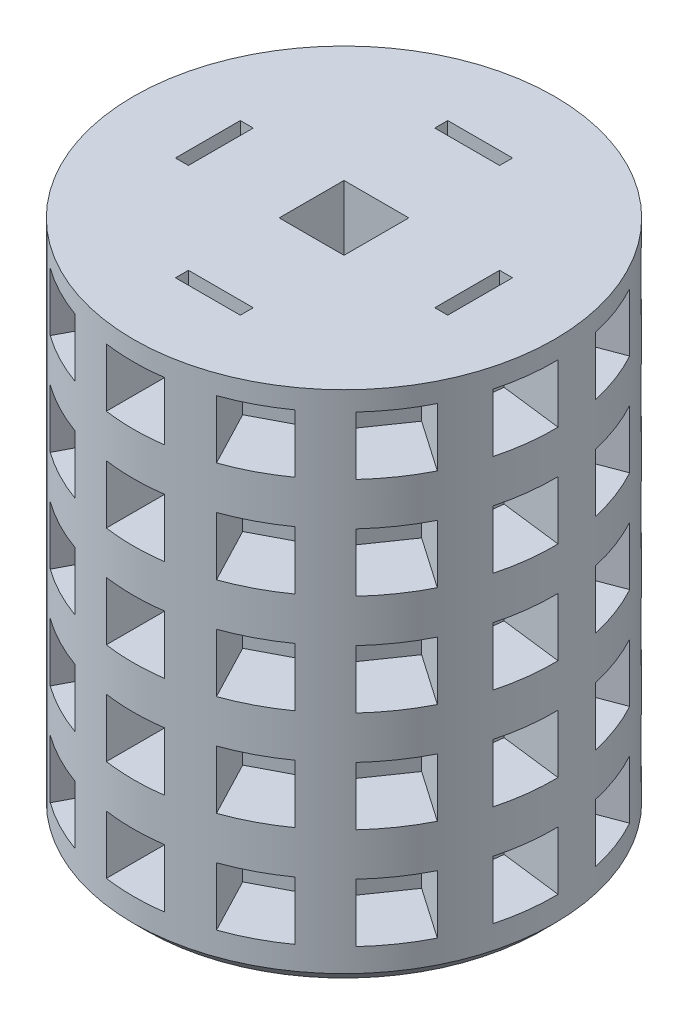
from build123d import *

# Parameters (mm, degrees)
SKETCH1_R                  = 41.2369
BOSS_EXTRUDE1_DEPTH        = 203.2
CUT_EXTRUDE1_DEPTH         = 204.2
CHAMFER1_SIZE              = 2.54
CHAMFER2_SIZE              = 2.54
CUT_EXTRUDE3_DEPTH         = 12.7
LPATTERN1_COUNT            = 10
LPATTERN1_PITCH            = 19.812
CIRPATTERN1_COUNT          = 13
CIRPATTERN1_ANGLE          = 332.4
CIRPATTERN1_COPY_1_DEPTH   = 12.7
CIRPATTERN1_COPY_2_DEPTH   = 12.7
CIRPATTERN1_COPY_3_DEPTH   = 12.7
CIRPATTERN1_COPY_4_DEPTH   = 12.7
CIRPATTERN1_COPY_5_DEPTH   = 12.7
CIRPATTERN1_COPY_6_DEPTH   = 12.7
CIRPATTERN1_COPY_7_DEPTH   = 12.7
CIRPATTERN1_COPY_8_DEPTH   = 12.7
CIRPATTERN1_COPY_9_DEPTH   = 12.7
CIRPATTERN1_COPY_10_DEPTH  = 12.7
CIRPATTERN1_COPY_11_DEPTH  = 12.7
CIRPATTERN1_COPY_12_DEPTH  = 12.7
CIRPATTERN1_COPY_13_DEPTH  = 12.7
CIRPATTERN1_COPY_14_DEPTH  = 12.7
CIRPATTERN1_COPY_15_DEPTH  = 12.7
CIRPATTERN1_COPY_16_DEPTH  = 12.7
CIRPATTERN1_COPY_17_DEPTH  = 12.7
CIRPATTERN1_COPY_18_DEPTH  = 12.7
CIRPATTERN1_COPY_19_DEPTH  = 12.7
CIRPATTERN1_COPY_20_DEPTH  = 12.7
CIRPATTERN1_COPY_21_DEPTH  = 12.7
CIRPATTERN1_COPY_22_DEPTH  = 12.7
CIRPATTERN1_COPY_23_DEPTH  = 12.7
CIRPATTERN1_COPY_24_DEPTH  = 12.7
CIRPATTERN1_COPY_25_DEPTH  = 12.7
CIRPATTERN1_COPY_26_DEPTH  = 12.7
CIRPATTERN1_COPY_27_DEPTH  = 12.7
CIRPATTERN1_COPY_28_DEPTH  = 12.7
CIRPATTERN1_COPY_29_DEPTH  = 12.7
CIRPATTERN1_COPY_30_DEPTH  = 12.7
CIRPATTERN1_COPY_31_DEPTH  = 12.7
CIRPATTERN1_COPY_32_DEPTH  = 12.7
CIRPATTERN1_COPY_33_DEPTH  = 12.7
CIRPATTERN1_COPY_34_DEPTH  = 12.7
CIRPATTERN1_COPY_35_DEPTH  = 12.7
CIRPATTERN1_COPY_36_DEPTH  = 12.7
CIRPATTERN1_COPY_37_DEPTH  = 12.7
CIRPATTERN1_COPY_38_DEPTH  = 12.7
CIRPATTERN1_COPY_39_DEPTH  = 12.7
CIRPATTERN1_COPY_40_DEPTH  = 12.7
CIRPATTERN1_COPY_41_DEPTH  = 12.7
CIRPATTERN1_COPY_42_DEPTH  = 12.7
CIRPATTERN1_COPY_43_DEPTH  = 12.7
CIRPATTERN1_COPY_44_DEPTH  = 12.7
CIRPATTERN1_COPY_45_DEPTH  = 12.7
CIRPATTERN1_COPY_46_DEPTH  = 12.7
CIRPATTERN1_COPY_47_DEPTH  = 12.7
CIRPATTERN1_COPY_48_DEPTH  = 12.7
CIRPATTERN1_COPY_49_DEPTH  = 12.7
CIRPATTERN1_COPY_50_DEPTH  = 12.7
CIRPATTERN1_COPY_51_DEPTH  = 12.7
CIRPATTERN1_COPY_52_DEPTH  = 12.7
CIRPATTERN1_COPY_53_DEPTH  = 12.7
CIRPATTERN1_COPY_54_DEPTH  = 12.7
CIRPATTERN1_COPY_55_DEPTH  = 12.7
CIRPATTERN1_COPY_56_DEPTH  = 12.7
CIRPATTERN1_COPY_57_DEPTH  = 12.7
CIRPATTERN1_COPY_58_DEPTH  = 12.7
CIRPATTERN1_COPY_59_DEPTH  = 12.7
CIRPATTERN1_COPY_60_DEPTH  = 12.7
CIRPATTERN1_COPY_61_DEPTH  = 12.7
CIRPATTERN1_COPY_62_DEPTH  = 12.7
CIRPATTERN1_COPY_63_DEPTH  = 12.7
CIRPATTERN1_COPY_64_DEPTH  = 12.7
CIRPATTERN1_COPY_65_DEPTH  = 12.7
CIRPATTERN1_COPY_66_DEPTH  = 12.7
CIRPATTERN1_COPY_67_DEPTH  = 12.7
CIRPATTERN1_COPY_68_DEPTH  = 12.7
CIRPATTERN1_COPY_69_DEPTH  = 12.7
CIRPATTERN1_COPY_70_DEPTH  = 12.7
CIRPATTERN1_COPY_71_DEPTH  = 12.7
CIRPATTERN1_COPY_72_DEPTH  = 12.7
CIRPATTERN1_COPY_73_DEPTH  = 12.7
CIRPATTERN1_COPY_74_DEPTH  = 12.7
CIRPATTERN1_COPY_75_DEPTH  = 12.7
CIRPATTERN1_COPY_76_DEPTH  = 12.7
CIRPATTERN1_COPY_77_DEPTH  = 12.7
CIRPATTERN1_COPY_78_DEPTH  = 12.7
CIRPATTERN1_COPY_79_DEPTH  = 12.7
CIRPATTERN1_COPY_80_DEPTH  = 12.7
CIRPATTERN1_COPY_81_DEPTH  = 12.7
CIRPATTERN1_COPY_82_DEPTH  = 12.7
CIRPATTERN1_COPY_83_DEPTH  = 12.7
CIRPATTERN1_COPY_84_DEPTH  = 12.7
CIRPATTERN1_COPY_85_DEPTH  = 12.7
CIRPATTERN1_COPY_86_DEPTH  = 12.7
CIRPATTERN1_COPY_87_DEPTH  = 12.7
CIRPATTERN1_COPY_88_DEPTH  = 12.7
CIRPATTERN1_COPY_89_DEPTH  = 12.7
CIRPATTERN1_COPY_90_DEPTH  = 12.7
CIRPATTERN1_COPY_91_DEPTH  = 12.7
CIRPATTERN1_COPY_92_DEPTH  = 12.7
CIRPATTERN1_COPY_93_DEPTH  = 12.7
CIRPATTERN1_COPY_94_DEPTH  = 12.7
CIRPATTERN1_COPY_95_DEPTH  = 12.7
CIRPATTERN1_COPY_96_DEPTH  = 12.7
CIRPATTERN1_COPY_97_DEPTH  = 12.7
CIRPATTERN1_COPY_98_DEPTH  = 12.7
CIRPATTERN1_COPY_99_DEPTH  = 12.7
CIRPATTERN1_COPY_100_DEPTH = 12.7
CIRPATTERN1_COPY_101_DEPTH = 12.7
CIRPATTERN1_COPY_102_DEPTH = 12.7
CIRPATTERN1_COPY_103_DEPTH = 12.7
CIRPATTERN1_COPY_104_DEPTH = 12.7
CIRPATTERN1_COPY_105_DEPTH = 12.7
CIRPATTERN1_COPY_106_DEPTH = 12.7
CIRPATTERN1_COPY_107_DEPTH = 12.7
CIRPATTERN1_COPY_108_DEPTH = 12.7
SKETCH7_R                  = 41.2369
CUT_EXTRUDE4_DEPTH         = 101.6
SKETCH9_R                  = 20.32
SKETCH9_W                  = 12.7
SKETCH9_H                  = 12.7
BOSS_EXTRUDE4_DEPTH        = 9.906
SKETCH8_W                  = 12.7
SKETCH8_H                  = 2.54
SKETCH8_W_2                = 2.54
SKETCH8_H_2                = 12.7
CUT_EXTRUDE6_DEPTH         = 12.7


with BuildPart() as part:
    # Sketch1 → Boss-Extrude1 (new body)
    with BuildSketch(Plane(origin=(0, 0, 0), x_dir=(1, 0, 0), z_dir=(0, 1, 0))):
        Circle(SKETCH1_R)
    extrude(amount=BOSS_EXTRUDE1_DEPTH)

    # Sketch2 → Cut-Extrude1 (cut, through all)
    with BuildSketch(Plane(origin=(0, 0, 0), x_dir=(-1, 0, 0), z_dir=(0, -1, 0))):
        Polygon((0, -6.35), (6.35, -6.35), (6.35, 6.35), (0, 6.35), (-6.35, 6.35), (-6.35, -6.35), align=None)
    extrude(amount=-CUT_EXTRUDE1_DEPTH, mode=Mode.SUBTRACT)

    # Chamfer1
    chamfer1_edges = [part.edges().sort_by_distance(p)[0] for p in [
        (-41.2369, 203.2, 0),
    ]]
    chamfer(chamfer1_edges, length=CHAMFER1_SIZE)

    # Chamfer2
    chamfer2_edges = [part.edges().sort_by_distance(p)[0] for p in [
        (-41.2369, 0, 0),
    ]]
    chamfer(chamfer2_edges, length=CHAMFER2_SIZE)

    # Sketch6 → Cut-Extrude3 (cut)
    with BuildSketch(Plane.XY.offset(41.402)):
        Polygon((0, 196.85), (5.715, 196.85), (5.715, 191.135), (5.715, 185.42), (-5.715, 185.42), (-5.715, 191.135), (-5.715, 196.85), align=None)
    cut_extrude3 = extrude(amount=-CUT_EXTRUDE3_DEPTH, mode=Mode.SUBTRACT)

    # LPattern1: Cut-Extrude3 ×10
    with Locations(*[(0, -i * LPATTERN1_PITCH, 0) for i in range(1, LPATTERN1_COUNT)]):
        add(cut_extrude3, mode=Mode.SUBTRACT)

    # CirPattern1: Cut-Extrude3 ×13 about axis
    cirpattern1_axis = Axis((0, 0, 0), (0, -1, 0))
    for i in range(1, CIRPATTERN1_COUNT):
        add(cut_extrude3.rotate(cirpattern1_axis, i * CIRPATTERN1_ANGLE / (CIRPATTERN1_COUNT - 1)), mode=Mode.SUBTRACT)

    # CirPattern1 copy 1 sketch → CirPattern1 copy 1 (cut)
    with BuildSketch(Plane(origin=(-19.245390377, -19.812, 36.657066893), x_dir=(0.885393626, 0, 0.464842046), z_dir=(-0.464842046, 0, 0.885393626))):
        Polygon((0, 196.85), (5.715, 196.85), (5.715, 191.135), (5.715, 185.42), (-5.715, 185.42), (-5.715, 191.135), (-5.715, 196.85), align=None)
    extrude(amount=-CIRPATTERN1_COPY_1_DEPTH, mode=Mode.SUBTRACT)

    # CirPattern1 copy 2 sketch → CirPattern1 copy 2 (cut)
    with BuildSketch(Plane(origin=(-34.07949193, -19.812, 23.509866733), x_dir=(0.567843745, 0, 0.823136369), z_dir=(-0.823136369, 0, 0.567843745))):
        Polygon((0, 196.85), (5.715, 196.85), (5.715, 191.135), (5.715, 185.42), (-5.715, 185.42), (-5.715, 191.135), (-5.715, 196.85), align=None)
    extrude(amount=-CIRPATTERN1_COPY_2_DEPTH, mode=Mode.SUBTRACT)

    # CirPattern1 copy 3 sketch → CirPattern1 copy 3 (cut)
    with BuildSketch(Plane(origin=(-41.102139471, -19.812, 4.973905401), x_dir=(0.120136839, 0, 0.992757342), z_dir=(-0.992757342, 0, 0.120136839))):
        Polygon((0, 196.85), (5.715, 196.85), (5.715, 191.135), (5.715, 185.42), (-5.715, 185.42), (-5.715, 191.135), (-5.715, 196.85), align=None)
    extrude(amount=-CIRPATTERN1_COPY_3_DEPTH, mode=Mode.SUBTRACT)

    # CirPattern1 copy 4 sketch → CirPattern1 copy 4 (cut)
    with BuildSketch(Plane(origin=(-38.703652654, -19.812, -14.702138458), x_dir=(-0.355106962, 0, 0.934825676), z_dir=(-0.934825676, 0, -0.355106962))):
        Polygon((0, 196.85), (5.715, 196.85), (5.715, 191.135), (5.715, 185.42), (-5.715, 185.42), (-5.715, 191.135), (-5.715, 196.85), align=None)
    extrude(amount=-CIRPATTERN1_COPY_4_DEPTH, mode=Mode.SUBTRACT)

    # CirPattern1 copy 5 sketch → CirPattern1 copy 5 (cut)
    with BuildSketch(Plane(origin=(-27.433795236, -19.812, -31.008264752), x_dir=(-0.748955721, 0, 0.662620048), z_dir=(-0.662620048, 0, -0.748955721))):
        Polygon((0, 196.85), (5.715, 196.85), (5.715, 191.135), (5.715, 185.42), (-5.715, 185.42), (-5.715, 191.135), (-5.715, 196.85), align=None)
    extrude(amount=-CIRPATTERN1_COPY_5_DEPTH, mode=Mode.SUBTRACT)

    # CirPattern1 copy 6 sketch → CirPattern1 copy 6 (cut)
    with BuildSketch(Plane(origin=(-9.875762211, -19.812, -40.206901457), x_dir=(-0.97113428, 0, 0.238533458), z_dir=(-0.238533458, 0, -0.97113428))):
        Polygon((0, 196.85), (5.715, 196.85), (5.715, 191.135), (5.715, 185.42), (-5.715, 185.42), (-5.715, 191.135), (-5.715, 196.85), align=None)
    extrude(amount=-CIRPATTERN1_COPY_6_DEPTH, mode=Mode.SUBTRACT)

    # CirPattern1 copy 7 sketch → CirPattern1 copy 7 (cut)
    with BuildSketch(Plane(origin=(9.945921415, -19.812, -40.18960377), x_dir=(-0.970716482, 0, -0.240228042), z_dir=(0.240228042, 0, -0.970716482))):
        Polygon((0, 196.85), (5.715, 196.85), (5.715, 191.135), (5.715, 185.42), (-5.715, 185.42), (-5.715, 191.135), (-5.715, 196.85), align=None)
    extrude(amount=-CIRPATTERN1_COPY_7_DEPTH, mode=Mode.SUBTRACT)

    # CirPattern1 copy 8 sketch → CirPattern1 copy 8 (cut)
    with BuildSketch(Plane(origin=(27.487873056, -19.812, -30.960336543), x_dir=(-0.74779809, 0, -0.663926213), z_dir=(0.663926213, 0, -0.74779809))):
        Polygon((0, 196.85), (5.715, 196.85), (5.715, 191.135), (5.715, 185.42), (-5.715, 185.42), (-5.715, 191.135), (-5.715, 196.85), align=None)
    extrude(amount=-CIRPATTERN1_COPY_8_DEPTH, mode=Mode.SUBTRACT)

    # CirPattern1 copy 9 sketch → CirPattern1 copy 9 (cut)
    with BuildSketch(Plane(origin=(38.729253764, -19.812, -14.634565482), x_dir=(-0.353474844, 0, -0.935444031), z_dir=(0.935444031, 0, -0.353474844))):
        Polygon((0, 196.85), (5.715, 196.85), (5.715, 191.135), (5.715, 185.42), (-5.715, 185.42), (-5.715, 191.135), (-5.715, 196.85), align=None)
    extrude(amount=-CIRPATTERN1_COPY_9_DEPTH, mode=Mode.SUBTRACT)

    # CirPattern1 copy 10 sketch → CirPattern1 copy 10 (cut)
    with BuildSketch(Plane(origin=(41.09339577, -19.812, 5.045634556), x_dir=(0.121869343, 0, -0.992546152), z_dir=(0.992546152, 0, 0.121869343))):
        Polygon((0, 196.85), (5.715, 196.85), (5.715, 191.135), (5.715, 185.42), (-5.715, 185.42), (-5.715, 191.135), (-5.715, 196.85), align=None)
    extrude(amount=-CIRPATTERN1_COPY_10_DEPTH, mode=Mode.SUBTRACT)

    # CirPattern1 copy 11 sketch → CirPattern1 copy 11 (cut)
    with BuildSketch(Plane(origin=(34.038407587, -19.812, 23.569310829), x_dir=(0.569279523, 0, -0.822144041), z_dir=(0.822144041, 0, 0.569279523))):
        Polygon((0, 196.85), (5.715, 196.85), (5.715, 191.135), (5.715, 185.42), (-5.715, 185.42), (-5.715, 191.135), (-5.715, 196.85), align=None)
    extrude(amount=-CIRPATTERN1_COPY_11_DEPTH, mode=Mode.SUBTRACT)

    # CirPattern1 copy 12 sketch → CirPattern1 copy 12 (cut)
    with BuildSketch(Plane(origin=(19.181382446, -19.812, 36.690600587), x_dir=(0.886203579, 0, -0.463296035), z_dir=(0.463296035, 0, 0.886203579))):
        Polygon((0, 196.85), (5.715, 196.85), (5.715, 191.135), (5.715, 185.42), (-5.715, 185.42), (-5.715, 191.135), (-5.715, 196.85), align=None)
    extrude(amount=-CIRPATTERN1_COPY_12_DEPTH, mode=Mode.SUBTRACT)

    # CirPattern1 copy 13 sketch → CirPattern1 copy 13 (cut)
    with BuildSketch(Plane(origin=(-19.245390377, -39.624, 36.657066893), x_dir=(0.885393626, 0, 0.464842046), z_dir=(-0.464842046, 0, 0.885393626))):
        Polygon((0, 196.85), (5.715, 196.85), (5.715, 191.135), (5.715, 185.42), (-5.715, 185.42), (-5.715, 191.135), (-5.715, 196.85), align=None)
    extrude(amount=-CIRPATTERN1_COPY_13_DEPTH, mode=Mode.SUBTRACT)

    # CirPattern1 copy 14 sketch → CirPattern1 copy 14 (cut)
    with BuildSketch(Plane(origin=(-34.07949193, -39.624, 23.509866733), x_dir=(0.567843745, 0, 0.823136369), z_dir=(-0.823136369, 0, 0.567843745))):
        Polygon((0, 196.85), (5.715, 196.85), (5.715, 191.135), (5.715, 185.42), (-5.715, 185.42), (-5.715, 191.135), (-5.715, 196.85), align=None)
    extrude(amount=-CIRPATTERN1_COPY_14_DEPTH, mode=Mode.SUBTRACT)

    # CirPattern1 copy 15 sketch → CirPattern1 copy 15 (cut)
    with BuildSketch(Plane(origin=(-41.102139471, -39.624, 4.973905401), x_dir=(0.120136839, 0, 0.992757342), z_dir=(-0.992757342, 0, 0.120136839))):
        Polygon((0, 196.85), (5.715, 196.85), (5.715, 191.135), (5.715, 185.42), (-5.715, 185.42), (-5.715, 191.135), (-5.715, 196.85), align=None)
    extrude(amount=-CIRPATTERN1_COPY_15_DEPTH, mode=Mode.SUBTRACT)

    # CirPattern1 copy 16 sketch → CirPattern1 copy 16 (cut)
    with BuildSketch(Plane(origin=(-38.703652654, -39.624, -14.702138458), x_dir=(-0.355106962, 0, 0.934825676), z_dir=(-0.934825676, 0, -0.355106962))):
        Polygon((0, 196.85), (5.715, 196.85), (5.715, 191.135), (5.715, 185.42), (-5.715, 185.42), (-5.715, 191.135), (-5.715, 196.85), align=None)
    extrude(amount=-CIRPATTERN1_COPY_16_DEPTH, mode=Mode.SUBTRACT)

    # CirPattern1 copy 17 sketch → CirPattern1 copy 17 (cut)
    with BuildSketch(Plane(origin=(-27.433795236, -39.624, -31.008264752), x_dir=(-0.748955721, 0, 0.662620048), z_dir=(-0.662620048, 0, -0.748955721))):
        Polygon((0, 196.85), (5.715, 196.85), (5.715, 191.135), (5.715, 185.42), (-5.715, 185.42), (-5.715, 191.135), (-5.715, 196.85), align=None)
    extrude(amount=-CIRPATTERN1_COPY_17_DEPTH, mode=Mode.SUBTRACT)

    # CirPattern1 copy 18 sketch → CirPattern1 copy 18 (cut)
    with BuildSketch(Plane(origin=(-9.875762211, -39.624, -40.206901457), x_dir=(-0.97113428, 0, 0.238533458), z_dir=(-0.238533458, 0, -0.97113428))):
        Polygon((0, 196.85), (5.715, 196.85), (5.715, 191.135), (5.715, 185.42), (-5.715, 185.42), (-5.715, 191.135), (-5.715, 196.85), align=None)
    extrude(amount=-CIRPATTERN1_COPY_18_DEPTH, mode=Mode.SUBTRACT)

    # CirPattern1 copy 19 sketch → CirPattern1 copy 19 (cut)
    with BuildSketch(Plane(origin=(9.945921415, -39.624, -40.18960377), x_dir=(-0.970716482, 0, -0.240228042), z_dir=(0.240228042, 0, -0.970716482))):
        Polygon((0, 196.85), (5.715, 196.85), (5.715, 191.135), (5.715, 185.42), (-5.715, 185.42), (-5.715, 191.135), (-5.715, 196.85), align=None)
    extrude(amount=-CIRPATTERN1_COPY_19_DEPTH, mode=Mode.SUBTRACT)

    # CirPattern1 copy 20 sketch → CirPattern1 copy 20 (cut)
    with BuildSketch(Plane(origin=(27.487873056, -39.624, -30.960336543), x_dir=(-0.74779809, 0, -0.663926213), z_dir=(0.663926213, 0, -0.74779809))):
        Polygon((0, 196.85), (5.715, 196.85), (5.715, 191.135), (5.715, 185.42), (-5.715, 185.42), (-5.715, 191.135), (-5.715, 196.85), align=None)
    extrude(amount=-CIRPATTERN1_COPY_20_DEPTH, mode=Mode.SUBTRACT)

    # CirPattern1 copy 21 sketch → CirPattern1 copy 21 (cut)
    with BuildSketch(Plane(origin=(38.729253764, -39.624, -14.634565482), x_dir=(-0.353474844, 0, -0.935444031), z_dir=(0.935444031, 0, -0.353474844))):
        Polygon((0, 196.85), (5.715, 196.85), (5.715, 191.135), (5.715, 185.42), (-5.715, 185.42), (-5.715, 191.135), (-5.715, 196.85), align=None)
    extrude(amount=-CIRPATTERN1_COPY_21_DEPTH, mode=Mode.SUBTRACT)

    # CirPattern1 copy 22 sketch → CirPattern1 copy 22 (cut)
    with BuildSketch(Plane(origin=(41.09339577, -39.624, 5.045634556), x_dir=(0.121869343, 0, -0.992546152), z_dir=(0.992546152, 0, 0.121869343))):
        Polygon((0, 196.85), (5.715, 196.85), (5.715, 191.135), (5.715, 185.42), (-5.715, 185.42), (-5.715, 191.135), (-5.715, 196.85), align=None)
    extrude(amount=-CIRPATTERN1_COPY_22_DEPTH, mode=Mode.SUBTRACT)

    # CirPattern1 copy 23 sketch → CirPattern1 copy 23 (cut)
    with BuildSketch(Plane(origin=(34.038407587, -39.624, 23.569310829), x_dir=(0.569279523, 0, -0.822144041), z_dir=(0.822144041, 0, 0.569279523))):
        Polygon((0, 196.85), (5.715, 196.85), (5.715, 191.135), (5.715, 185.42), (-5.715, 185.42), (-5.715, 191.135), (-5.715, 196.85), align=None)
    extrude(amount=-CIRPATTERN1_COPY_23_DEPTH, mode=Mode.SUBTRACT)

    # CirPattern1 copy 24 sketch → CirPattern1 copy 24 (cut)
    with BuildSketch(Plane(origin=(19.181382446, -39.624, 36.690600587), x_dir=(0.886203579, 0, -0.463296035), z_dir=(0.463296035, 0, 0.886203579))):
        Polygon((0, 196.85), (5.715, 196.85), (5.715, 191.135), (5.715, 185.42), (-5.715, 185.42), (-5.715, 191.135), (-5.715, 196.85), align=None)
    extrude(amount=-CIRPATTERN1_COPY_24_DEPTH, mode=Mode.SUBTRACT)

    # CirPattern1 copy 25 sketch → CirPattern1 copy 25 (cut)
    with BuildSketch(Plane(origin=(-19.245390377, -59.436, 36.657066893), x_dir=(0.885393626, 0, 0.464842046), z_dir=(-0.464842046, 0, 0.885393626))):
        Polygon((0, 196.85), (5.715, 196.85), (5.715, 191.135), (5.715, 185.42), (-5.715, 185.42), (-5.715, 191.135), (-5.715, 196.85), align=None)
    extrude(amount=-CIRPATTERN1_COPY_25_DEPTH, mode=Mode.SUBTRACT)

    # CirPattern1 copy 26 sketch → CirPattern1 copy 26 (cut)
    with BuildSketch(Plane(origin=(-34.07949193, -59.436, 23.509866733), x_dir=(0.567843745, 0, 0.823136369), z_dir=(-0.823136369, 0, 0.567843745))):
        Polygon((0, 196.85), (5.715, 196.85), (5.715, 191.135), (5.715, 185.42), (-5.715, 185.42), (-5.715, 191.135), (-5.715, 196.85), align=None)
    extrude(amount=-CIRPATTERN1_COPY_26_DEPTH, mode=Mode.SUBTRACT)

    # CirPattern1 copy 27 sketch → CirPattern1 copy 27 (cut)
    with BuildSketch(Plane(origin=(-41.102139471, -59.436, 4.973905401), x_dir=(0.120136839, 0, 0.992757342), z_dir=(-0.992757342, 0, 0.120136839))):
        Polygon((0, 196.85), (5.715, 196.85), (5.715, 191.135), (5.715, 185.42), (-5.715, 185.42), (-5.715, 191.135), (-5.715, 196.85), align=None)
    extrude(amount=-CIRPATTERN1_COPY_27_DEPTH, mode=Mode.SUBTRACT)

    # CirPattern1 copy 28 sketch → CirPattern1 copy 28 (cut)
    with BuildSketch(Plane(origin=(-38.703652654, -59.436, -14.702138458), x_dir=(-0.355106962, 0, 0.934825676), z_dir=(-0.934825676, 0, -0.355106962))):
        Polygon((0, 196.85), (5.715, 196.85), (5.715, 191.135), (5.715, 185.42), (-5.715, 185.42), (-5.715, 191.135), (-5.715, 196.85), align=None)
    extrude(amount=-CIRPATTERN1_COPY_28_DEPTH, mode=Mode.SUBTRACT)

    # CirPattern1 copy 29 sketch → CirPattern1 copy 29 (cut)
    with BuildSketch(Plane(origin=(-27.433795236, -59.436, -31.008264752), x_dir=(-0.748955721, 0, 0.662620048), z_dir=(-0.662620048, 0, -0.748955721))):
        Polygon((0, 196.85), (5.715, 196.85), (5.715, 191.135), (5.715, 185.42), (-5.715, 185.42), (-5.715, 191.135), (-5.715, 196.85), align=None)
    extrude(amount=-CIRPATTERN1_COPY_29_DEPTH, mode=Mode.SUBTRACT)

    # CirPattern1 copy 30 sketch → CirPattern1 copy 30 (cut)
    with BuildSketch(Plane(origin=(-9.875762211, -59.436, -40.206901457), x_dir=(-0.97113428, 0, 0.238533458), z_dir=(-0.238533458, 0, -0.97113428))):
        Polygon((0, 196.85), (5.715, 196.85), (5.715, 191.135), (5.715, 185.42), (-5.715, 185.42), (-5.715, 191.135), (-5.715, 196.85), align=None)
    extrude(amount=-CIRPATTERN1_COPY_30_DEPTH, mode=Mode.SUBTRACT)

    # CirPattern1 copy 31 sketch → CirPattern1 copy 31 (cut)
    with BuildSketch(Plane(origin=(9.945921415, -59.436, -40.18960377), x_dir=(-0.970716482, 0, -0.240228042), z_dir=(0.240228042, 0, -0.970716482))):
        Polygon((0, 196.85), (5.715, 196.85), (5.715, 191.135), (5.715, 185.42), (-5.715, 185.42), (-5.715, 191.135), (-5.715, 196.85), align=None)
    extrude(amount=-CIRPATTERN1_COPY_31_DEPTH, mode=Mode.SUBTRACT)

    # CirPattern1 copy 32 sketch → CirPattern1 copy 32 (cut)
    with BuildSketch(Plane(origin=(27.487873056, -59.436, -30.960336543), x_dir=(-0.74779809, 0, -0.663926213), z_dir=(0.663926213, 0, -0.74779809))):
        Polygon((0, 196.85), (5.715, 196.85), (5.715, 191.135), (5.715, 185.42), (-5.715, 185.42), (-5.715, 191.135), (-5.715, 196.85), align=None)
    extrude(amount=-CIRPATTERN1_COPY_32_DEPTH, mode=Mode.SUBTRACT)

    # CirPattern1 copy 33 sketch → CirPattern1 copy 33 (cut)
    with BuildSketch(Plane(origin=(38.729253764, -59.436, -14.634565482), x_dir=(-0.353474844, 0, -0.935444031), z_dir=(0.935444031, 0, -0.353474844))):
        Polygon((0, 196.85), (5.715, 196.85), (5.715, 191.135), (5.715, 185.42), (-5.715, 185.42), (-5.715, 191.135), (-5.715, 196.85), align=None)
    extrude(amount=-CIRPATTERN1_COPY_33_DEPTH, mode=Mode.SUBTRACT)

    # CirPattern1 copy 34 sketch → CirPattern1 copy 34 (cut)
    with BuildSketch(Plane(origin=(41.09339577, -59.436, 5.045634556), x_dir=(0.121869343, 0, -0.992546152), z_dir=(0.992546152, 0, 0.121869343))):
        Polygon((0, 196.85), (5.715, 196.85), (5.715, 191.135), (5.715, 185.42), (-5.715, 185.42), (-5.715, 191.135), (-5.715, 196.85), align=None)
    extrude(amount=-CIRPATTERN1_COPY_34_DEPTH, mode=Mode.SUBTRACT)

    # CirPattern1 copy 35 sketch → CirPattern1 copy 35 (cut)
    with BuildSketch(Plane(origin=(34.038407587, -59.436, 23.569310829), x_dir=(0.569279523, 0, -0.822144041), z_dir=(0.822144041, 0, 0.569279523))):
        Polygon((0, 196.85), (5.715, 196.85), (5.715, 191.135), (5.715, 185.42), (-5.715, 185.42), (-5.715, 191.135), (-5.715, 196.85), align=None)
    extrude(amount=-CIRPATTERN1_COPY_35_DEPTH, mode=Mode.SUBTRACT)

    # CirPattern1 copy 36 sketch → CirPattern1 copy 36 (cut)
    with BuildSketch(Plane(origin=(19.181382446, -59.436, 36.690600587), x_dir=(0.886203579, 0, -0.463296035), z_dir=(0.463296035, 0, 0.886203579))):
        Polygon((0, 196.85), (5.715, 196.85), (5.715, 191.135), (5.715, 185.42), (-5.715, 185.42), (-5.715, 191.135), (-5.715, 196.85), align=None)
    extrude(amount=-CIRPATTERN1_COPY_36_DEPTH, mode=Mode.SUBTRACT)

    # CirPattern1 copy 37 sketch → CirPattern1 copy 37 (cut)
    with BuildSketch(Plane(origin=(-19.245390377, -79.248, 36.657066893), x_dir=(0.885393626, 0, 0.464842046), z_dir=(-0.464842046, 0, 0.885393626))):
        Polygon((0, 196.85), (5.715, 196.85), (5.715, 191.135), (5.715, 185.42), (-5.715, 185.42), (-5.715, 191.135), (-5.715, 196.85), align=None)
    extrude(amount=-CIRPATTERN1_COPY_37_DEPTH, mode=Mode.SUBTRACT)

    # CirPattern1 copy 38 sketch → CirPattern1 copy 38 (cut)
    with BuildSketch(Plane(origin=(-34.07949193, -79.248, 23.509866733), x_dir=(0.567843745, 0, 0.823136369), z_dir=(-0.823136369, 0, 0.567843745))):
        Polygon((0, 196.85), (5.715, 196.85), (5.715, 191.135), (5.715, 185.42), (-5.715, 185.42), (-5.715, 191.135), (-5.715, 196.85), align=None)
    extrude(amount=-CIRPATTERN1_COPY_38_DEPTH, mode=Mode.SUBTRACT)

    # CirPattern1 copy 39 sketch → CirPattern1 copy 39 (cut)
    with BuildSketch(Plane(origin=(-41.102139471, -79.248, 4.973905401), x_dir=(0.120136839, 0, 0.992757342), z_dir=(-0.992757342, 0, 0.120136839))):
        Polygon((0, 196.85), (5.715, 196.85), (5.715, 191.135), (5.715, 185.42), (-5.715, 185.42), (-5.715, 191.135), (-5.715, 196.85), align=None)
    extrude(amount=-CIRPATTERN1_COPY_39_DEPTH, mode=Mode.SUBTRACT)

    # CirPattern1 copy 40 sketch → CirPattern1 copy 40 (cut)
    with BuildSketch(Plane(origin=(-38.703652654, -79.248, -14.702138458), x_dir=(-0.355106962, 0, 0.934825676), z_dir=(-0.934825676, 0, -0.355106962))):
        Polygon((0, 196.85), (5.715, 196.85), (5.715, 191.135), (5.715, 185.42), (-5.715, 185.42), (-5.715, 191.135), (-5.715, 196.85), align=None)
    extrude(amount=-CIRPATTERN1_COPY_40_DEPTH, mode=Mode.SUBTRACT)

    # CirPattern1 copy 41 sketch → CirPattern1 copy 41 (cut)
    with BuildSketch(Plane(origin=(-27.433795236, -79.248, -31.008264752), x_dir=(-0.748955721, 0, 0.662620048), z_dir=(-0.662620048, 0, -0.748955721))):
        Polygon((0, 196.85), (5.715, 196.85), (5.715, 191.135), (5.715, 185.42), (-5.715, 185.42), (-5.715, 191.135), (-5.715, 196.85), align=None)
    extrude(amount=-CIRPATTERN1_COPY_41_DEPTH, mode=Mode.SUBTRACT)

    # CirPattern1 copy 42 sketch → CirPattern1 copy 42 (cut)
    with BuildSketch(Plane(origin=(-9.875762211, -79.248, -40.206901457), x_dir=(-0.97113428, 0, 0.238533458), z_dir=(-0.238533458, 0, -0.97113428))):
        Polygon((0, 196.85), (5.715, 196.85), (5.715, 191.135), (5.715, 185.42), (-5.715, 185.42), (-5.715, 191.135), (-5.715, 196.85), align=None)
    extrude(amount=-CIRPATTERN1_COPY_42_DEPTH, mode=Mode.SUBTRACT)

    # CirPattern1 copy 43 sketch → CirPattern1 copy 43 (cut)
    with BuildSketch(Plane(origin=(9.945921415, -79.248, -40.18960377), x_dir=(-0.970716482, 0, -0.240228042), z_dir=(0.240228042, 0, -0.970716482))):
        Polygon((0, 196.85), (5.715, 196.85), (5.715, 191.135), (5.715, 185.42), (-5.715, 185.42), (-5.715, 191.135), (-5.715, 196.85), align=None)
    extrude(amount=-CIRPATTERN1_COPY_43_DEPTH, mode=Mode.SUBTRACT)

    # CirPattern1 copy 44 sketch → CirPattern1 copy 44 (cut)
    with BuildSketch(Plane(origin=(27.487873056, -79.248, -30.960336543), x_dir=(-0.74779809, 0, -0.663926213), z_dir=(0.663926213, 0, -0.74779809))):
        Polygon((0, 196.85), (5.715, 196.85), (5.715, 191.135), (5.715, 185.42), (-5.715, 185.42), (-5.715, 191.135), (-5.715, 196.85), align=None)
    extrude(amount=-CIRPATTERN1_COPY_44_DEPTH, mode=Mode.SUBTRACT)

    # CirPattern1 copy 45 sketch → CirPattern1 copy 45 (cut)
    with BuildSketch(Plane(origin=(38.729253764, -79.248, -14.634565482), x_dir=(-0.353474844, 0, -0.935444031), z_dir=(0.935444031, 0, -0.353474844))):
        Polygon((0, 196.85), (5.715, 196.85), (5.715, 191.135), (5.715, 185.42), (-5.715, 185.42), (-5.715, 191.135), (-5.715, 196.85), align=None)
    extrude(amount=-CIRPATTERN1_COPY_45_DEPTH, mode=Mode.SUBTRACT)

    # CirPattern1 copy 46 sketch → CirPattern1 copy 46 (cut)
    with BuildSketch(Plane(origin=(41.09339577, -79.248, 5.045634556), x_dir=(0.121869343, 0, -0.992546152), z_dir=(0.992546152, 0, 0.121869343))):
        Polygon((0, 196.85), (5.715, 196.85), (5.715, 191.135), (5.715, 185.42), (-5.715, 185.42), (-5.715, 191.135), (-5.715, 196.85), align=None)
    extrude(amount=-CIRPATTERN1_COPY_46_DEPTH, mode=Mode.SUBTRACT)

    # CirPattern1 copy 47 sketch → CirPattern1 copy 47 (cut)
    with BuildSketch(Plane(origin=(34.038407587, -79.248, 23.569310829), x_dir=(0.569279523, 0, -0.822144041), z_dir=(0.822144041, 0, 0.569279523))):
        Polygon((0, 196.85), (5.715, 196.85), (5.715, 191.135), (5.715, 185.42), (-5.715, 185.42), (-5.715, 191.135), (-5.715, 196.85), align=None)
    extrude(amount=-CIRPATTERN1_COPY_47_DEPTH, mode=Mode.SUBTRACT)

    # CirPattern1 copy 48 sketch → CirPattern1 copy 48 (cut)
    with BuildSketch(Plane(origin=(19.181382446, -79.248, 36.690600587), x_dir=(0.886203579, 0, -0.463296035), z_dir=(0.463296035, 0, 0.886203579))):
        Polygon((0, 196.85), (5.715, 196.85), (5.715, 191.135), (5.715, 185.42), (-5.715, 185.42), (-5.715, 191.135), (-5.715, 196.85), align=None)
    extrude(amount=-CIRPATTERN1_COPY_48_DEPTH, mode=Mode.SUBTRACT)

    # CirPattern1 copy 49 sketch → CirPattern1 copy 49 (cut)
    with BuildSketch(Plane(origin=(-19.245390377, -99.06, 36.657066893), x_dir=(0.885393626, 0, 0.464842046), z_dir=(-0.464842046, 0, 0.885393626))):
        Polygon((0, 196.85), (5.715, 196.85), (5.715, 191.135), (5.715, 185.42), (-5.715, 185.42), (-5.715, 191.135), (-5.715, 196.85), align=None)
    extrude(amount=-CIRPATTERN1_COPY_49_DEPTH, mode=Mode.SUBTRACT)

    # CirPattern1 copy 50 sketch → CirPattern1 copy 50 (cut)
    with BuildSketch(Plane(origin=(-34.07949193, -99.06, 23.509866733), x_dir=(0.567843745, 0, 0.823136369), z_dir=(-0.823136369, 0, 0.567843745))):
        Polygon((0, 196.85), (5.715, 196.85), (5.715, 191.135), (5.715, 185.42), (-5.715, 185.42), (-5.715, 191.135), (-5.715, 196.85), align=None)
    extrude(amount=-CIRPATTERN1_COPY_50_DEPTH, mode=Mode.SUBTRACT)

    # CirPattern1 copy 51 sketch → CirPattern1 copy 51 (cut)
    with BuildSketch(Plane(origin=(-41.102139471, -99.06, 4.973905401), x_dir=(0.120136839, 0, 0.992757342), z_dir=(-0.992757342, 0, 0.120136839))):
        Polygon((0, 196.85), (5.715, 196.85), (5.715, 191.135), (5.715, 185.42), (-5.715, 185.42), (-5.715, 191.135), (-5.715, 196.85), align=None)
    extrude(amount=-CIRPATTERN1_COPY_51_DEPTH, mode=Mode.SUBTRACT)

    # CirPattern1 copy 52 sketch → CirPattern1 copy 52 (cut)
    with BuildSketch(Plane(origin=(-38.703652654, -99.06, -14.702138458), x_dir=(-0.355106962, 0, 0.934825676), z_dir=(-0.934825676, 0, -0.355106962))):
        Polygon((0, 196.85), (5.715, 196.85), (5.715, 191.135), (5.715, 185.42), (-5.715, 185.42), (-5.715, 191.135), (-5.715, 196.85), align=None)
    extrude(amount=-CIRPATTERN1_COPY_52_DEPTH, mode=Mode.SUBTRACT)

    # CirPattern1 copy 53 sketch → CirPattern1 copy 53 (cut)
    with BuildSketch(Plane(origin=(-27.433795236, -99.06, -31.008264752), x_dir=(-0.748955721, 0, 0.662620048), z_dir=(-0.662620048, 0, -0.748955721))):
        Polygon((0, 196.85), (5.715, 196.85), (5.715, 191.135), (5.715, 185.42), (-5.715, 185.42), (-5.715, 191.135), (-5.715, 196.85), align=None)
    extrude(amount=-CIRPATTERN1_COPY_53_DEPTH, mode=Mode.SUBTRACT)

    # CirPattern1 copy 54 sketch → CirPattern1 copy 54 (cut)
    with BuildSketch(Plane(origin=(-9.875762211, -99.06, -40.206901457), x_dir=(-0.97113428, 0, 0.238533458), z_dir=(-0.238533458, 0, -0.97113428))):
        Polygon((0, 196.85), (5.715, 196.85), (5.715, 191.135), (5.715, 185.42), (-5.715, 185.42), (-5.715, 191.135), (-5.715, 196.85), align=None)
    extrude(amount=-CIRPATTERN1_COPY_54_DEPTH, mode=Mode.SUBTRACT)

    # CirPattern1 copy 55 sketch → CirPattern1 copy 55 (cut)
    with BuildSketch(Plane(origin=(9.945921415, -99.06, -40.18960377), x_dir=(-0.970716482, 0, -0.240228042), z_dir=(0.240228042, 0, -0.970716482))):
        Polygon((0, 196.85), (5.715, 196.85), (5.715, 191.135), (5.715, 185.42), (-5.715, 185.42), (-5.715, 191.135), (-5.715, 196.85), align=None)
    extrude(amount=-CIRPATTERN1_COPY_55_DEPTH, mode=Mode.SUBTRACT)

    # CirPattern1 copy 56 sketch → CirPattern1 copy 56 (cut)
    with BuildSketch(Plane(origin=(27.487873056, -99.06, -30.960336543), x_dir=(-0.74779809, 0, -0.663926213), z_dir=(0.663926213, 0, -0.74779809))):
        Polygon((0, 196.85), (5.715, 196.85), (5.715, 191.135), (5.715, 185.42), (-5.715, 185.42), (-5.715, 191.135), (-5.715, 196.85), align=None)
    extrude(amount=-CIRPATTERN1_COPY_56_DEPTH, mode=Mode.SUBTRACT)

    # CirPattern1 copy 57 sketch → CirPattern1 copy 57 (cut)
    with BuildSketch(Plane(origin=(38.729253764, -99.06, -14.634565482), x_dir=(-0.353474844, 0, -0.935444031), z_dir=(0.935444031, 0, -0.353474844))):
        Polygon((0, 196.85), (5.715, 196.85), (5.715, 191.135), (5.715, 185.42), (-5.715, 185.42), (-5.715, 191.135), (-5.715, 196.85), align=None)
    extrude(amount=-CIRPATTERN1_COPY_57_DEPTH, mode=Mode.SUBTRACT)

    # CirPattern1 copy 58 sketch → CirPattern1 copy 58 (cut)
    with BuildSketch(Plane(origin=(41.09339577, -99.06, 5.045634556), x_dir=(0.121869343, 0, -0.992546152), z_dir=(0.992546152, 0, 0.121869343))):
        Polygon((0, 196.85), (5.715, 196.85), (5.715, 191.135), (5.715, 185.42), (-5.715, 185.42), (-5.715, 191.135), (-5.715, 196.85), align=None)
    extrude(amount=-CIRPATTERN1_COPY_58_DEPTH, mode=Mode.SUBTRACT)

    # CirPattern1 copy 59 sketch → CirPattern1 copy 59 (cut)
    with BuildSketch(Plane(origin=(34.038407587, -99.06, 23.569310829), x_dir=(0.569279523, 0, -0.822144041), z_dir=(0.822144041, 0, 0.569279523))):
        Polygon((0, 196.85), (5.715, 196.85), (5.715, 191.135), (5.715, 185.42), (-5.715, 185.42), (-5.715, 191.135), (-5.715, 196.85), align=None)
    extrude(amount=-CIRPATTERN1_COPY_59_DEPTH, mode=Mode.SUBTRACT)

    # CirPattern1 copy 60 sketch → CirPattern1 copy 60 (cut)
    with BuildSketch(Plane(origin=(19.181382446, -99.06, 36.690600587), x_dir=(0.886203579, 0, -0.463296035), z_dir=(0.463296035, 0, 0.886203579))):
        Polygon((0, 196.85), (5.715, 196.85), (5.715, 191.135), (5.715, 185.42), (-5.715, 185.42), (-5.715, 191.135), (-5.715, 196.85), align=None)
    extrude(amount=-CIRPATTERN1_COPY_60_DEPTH, mode=Mode.SUBTRACT)

    # CirPattern1 copy 61 sketch → CirPattern1 copy 61 (cut)
    with BuildSketch(Plane(origin=(-19.245390377, -118.872, 36.657066893), x_dir=(0.885393626, 0, 0.464842046), z_dir=(-0.464842046, 0, 0.885393626))):
        Polygon((0, 196.85), (5.715, 196.85), (5.715, 191.135), (5.715, 185.42), (-5.715, 185.42), (-5.715, 191.135), (-5.715, 196.85), align=None)
    extrude(amount=-CIRPATTERN1_COPY_61_DEPTH, mode=Mode.SUBTRACT)

    # CirPattern1 copy 62 sketch → CirPattern1 copy 62 (cut)
    with BuildSketch(Plane(origin=(-34.07949193, -118.872, 23.509866733), x_dir=(0.567843745, 0, 0.823136369), z_dir=(-0.823136369, 0, 0.567843745))):
        Polygon((0, 196.85), (5.715, 196.85), (5.715, 191.135), (5.715, 185.42), (-5.715, 185.42), (-5.715, 191.135), (-5.715, 196.85), align=None)
    extrude(amount=-CIRPATTERN1_COPY_62_DEPTH, mode=Mode.SUBTRACT)

    # CirPattern1 copy 63 sketch → CirPattern1 copy 63 (cut)
    with BuildSketch(Plane(origin=(-41.102139471, -118.872, 4.973905401), x_dir=(0.120136839, 0, 0.992757342), z_dir=(-0.992757342, 0, 0.120136839))):
        Polygon((0, 196.85), (5.715, 196.85), (5.715, 191.135), (5.715, 185.42), (-5.715, 185.42), (-5.715, 191.135), (-5.715, 196.85), align=None)
    extrude(amount=-CIRPATTERN1_COPY_63_DEPTH, mode=Mode.SUBTRACT)

    # CirPattern1 copy 64 sketch → CirPattern1 copy 64 (cut)
    with BuildSketch(Plane(origin=(-38.703652654, -118.872, -14.702138458), x_dir=(-0.355106962, 0, 0.934825676), z_dir=(-0.934825676, 0, -0.355106962))):
        Polygon((0, 196.85), (5.715, 196.85), (5.715, 191.135), (5.715, 185.42), (-5.715, 185.42), (-5.715, 191.135), (-5.715, 196.85), align=None)
    extrude(amount=-CIRPATTERN1_COPY_64_DEPTH, mode=Mode.SUBTRACT)

    # CirPattern1 copy 65 sketch → CirPattern1 copy 65 (cut)
    with BuildSketch(Plane(origin=(-27.433795236, -118.872, -31.008264752), x_dir=(-0.748955721, 0, 0.662620048), z_dir=(-0.662620048, 0, -0.748955721))):
        Polygon((0, 196.85), (5.715, 196.85), (5.715, 191.135), (5.715, 185.42), (-5.715, 185.42), (-5.715, 191.135), (-5.715, 196.85), align=None)
    extrude(amount=-CIRPATTERN1_COPY_65_DEPTH, mode=Mode.SUBTRACT)

    # CirPattern1 copy 66 sketch → CirPattern1 copy 66 (cut)
    with BuildSketch(Plane(origin=(-9.875762211, -118.872, -40.206901457), x_dir=(-0.97113428, 0, 0.238533458), z_dir=(-0.238533458, 0, -0.97113428))):
        Polygon((0, 196.85), (5.715, 196.85), (5.715, 191.135), (5.715, 185.42), (-5.715, 185.42), (-5.715, 191.135), (-5.715, 196.85), align=None)
    extrude(amount=-CIRPATTERN1_COPY_66_DEPTH, mode=Mode.SUBTRACT)

    # CirPattern1 copy 67 sketch → CirPattern1 copy 67 (cut)
    with BuildSketch(Plane(origin=(9.945921415, -118.872, -40.18960377), x_dir=(-0.970716482, 0, -0.240228042), z_dir=(0.240228042, 0, -0.970716482))):
        Polygon((0, 196.85), (5.715, 196.85), (5.715, 191.135), (5.715, 185.42), (-5.715, 185.42), (-5.715, 191.135), (-5.715, 196.85), align=None)
    extrude(amount=-CIRPATTERN1_COPY_67_DEPTH, mode=Mode.SUBTRACT)

    # CirPattern1 copy 68 sketch → CirPattern1 copy 68 (cut)
    with BuildSketch(Plane(origin=(27.487873056, -118.872, -30.960336543), x_dir=(-0.74779809, 0, -0.663926213), z_dir=(0.663926213, 0, -0.74779809))):
        Polygon((0, 196.85), (5.715, 196.85), (5.715, 191.135), (5.715, 185.42), (-5.715, 185.42), (-5.715, 191.135), (-5.715, 196.85), align=None)
    extrude(amount=-CIRPATTERN1_COPY_68_DEPTH, mode=Mode.SUBTRACT)

    # CirPattern1 copy 69 sketch → CirPattern1 copy 69 (cut)
    with BuildSketch(Plane(origin=(38.729253764, -118.872, -14.634565482), x_dir=(-0.353474844, 0, -0.935444031), z_dir=(0.935444031, 0, -0.353474844))):
        Polygon((0, 196.85), (5.715, 196.85), (5.715, 191.135), (5.715, 185.42), (-5.715, 185.42), (-5.715, 191.135), (-5.715, 196.85), align=None)
    extrude(amount=-CIRPATTERN1_COPY_69_DEPTH, mode=Mode.SUBTRACT)

    # CirPattern1 copy 70 sketch → CirPattern1 copy 70 (cut)
    with BuildSketch(Plane(origin=(41.09339577, -118.872, 5.045634556), x_dir=(0.121869343, 0, -0.992546152), z_dir=(0.992546152, 0, 0.121869343))):
        Polygon((0, 196.85), (5.715, 196.85), (5.715, 191.135), (5.715, 185.42), (-5.715, 185.42), (-5.715, 191.135), (-5.715, 196.85), align=None)
    extrude(amount=-CIRPATTERN1_COPY_70_DEPTH, mode=Mode.SUBTRACT)

    # CirPattern1 copy 71 sketch → CirPattern1 copy 71 (cut)
    with BuildSketch(Plane(origin=(34.038407587, -118.872, 23.569310829), x_dir=(0.569279523, 0, -0.822144041), z_dir=(0.822144041, 0, 0.569279523))):
        Polygon((0, 196.85), (5.715, 196.85), (5.715, 191.135), (5.715, 185.42), (-5.715, 185.42), (-5.715, 191.135), (-5.715, 196.85), align=None)
    extrude(amount=-CIRPATTERN1_COPY_71_DEPTH, mode=Mode.SUBTRACT)

    # CirPattern1 copy 72 sketch → CirPattern1 copy 72 (cut)
    with BuildSketch(Plane(origin=(19.181382446, -118.872, 36.690600587), x_dir=(0.886203579, 0, -0.463296035), z_dir=(0.463296035, 0, 0.886203579))):
        Polygon((0, 196.85), (5.715, 196.85), (5.715, 191.135), (5.715, 185.42), (-5.715, 185.42), (-5.715, 191.135), (-5.715, 196.85), align=None)
    extrude(amount=-CIRPATTERN1_COPY_72_DEPTH, mode=Mode.SUBTRACT)

    # CirPattern1 copy 73 sketch → CirPattern1 copy 73 (cut)
    with BuildSketch(Plane(origin=(-19.245390377, -138.684, 36.657066893), x_dir=(0.885393626, 0, 0.464842046), z_dir=(-0.464842046, 0, 0.885393626))):
        Polygon((0, 196.85), (5.715, 196.85), (5.715, 191.135), (5.715, 185.42), (-5.715, 185.42), (-5.715, 191.135), (-5.715, 196.85), align=None)
    extrude(amount=-CIRPATTERN1_COPY_73_DEPTH, mode=Mode.SUBTRACT)

    # CirPattern1 copy 74 sketch → CirPattern1 copy 74 (cut)
    with BuildSketch(Plane(origin=(-34.07949193, -138.684, 23.509866733), x_dir=(0.567843745, 0, 0.823136369), z_dir=(-0.823136369, 0, 0.567843745))):
        Polygon((0, 196.85), (5.715, 196.85), (5.715, 191.135), (5.715, 185.42), (-5.715, 185.42), (-5.715, 191.135), (-5.715, 196.85), align=None)
    extrude(amount=-CIRPATTERN1_COPY_74_DEPTH, mode=Mode.SUBTRACT)

    # CirPattern1 copy 75 sketch → CirPattern1 copy 75 (cut)
    with BuildSketch(Plane(origin=(-41.102139471, -138.684, 4.973905401), x_dir=(0.120136839, 0, 0.992757342), z_dir=(-0.992757342, 0, 0.120136839))):
        Polygon((0, 196.85), (5.715, 196.85), (5.715, 191.135), (5.715, 185.42), (-5.715, 185.42), (-5.715, 191.135), (-5.715, 196.85), align=None)
    extrude(amount=-CIRPATTERN1_COPY_75_DEPTH, mode=Mode.SUBTRACT)

    # CirPattern1 copy 76 sketch → CirPattern1 copy 76 (cut)
    with BuildSketch(Plane(origin=(-38.703652654, -138.684, -14.702138458), x_dir=(-0.355106962, 0, 0.934825676), z_dir=(-0.934825676, 0, -0.355106962))):
        Polygon((0, 196.85), (5.715, 196.85), (5.715, 191.135), (5.715, 185.42), (-5.715, 185.42), (-5.715, 191.135), (-5.715, 196.85), align=None)
    extrude(amount=-CIRPATTERN1_COPY_76_DEPTH, mode=Mode.SUBTRACT)

    # CirPattern1 copy 77 sketch → CirPattern1 copy 77 (cut)
    with BuildSketch(Plane(origin=(-27.433795236, -138.684, -31.008264752), x_dir=(-0.748955721, 0, 0.662620048), z_dir=(-0.662620048, 0, -0.748955721))):
        Polygon((0, 196.85), (5.715, 196.85), (5.715, 191.135), (5.715, 185.42), (-5.715, 185.42), (-5.715, 191.135), (-5.715, 196.85), align=None)
    extrude(amount=-CIRPATTERN1_COPY_77_DEPTH, mode=Mode.SUBTRACT)

    # CirPattern1 copy 78 sketch → CirPattern1 copy 78 (cut)
    with BuildSketch(Plane(origin=(-9.875762211, -138.684, -40.206901457), x_dir=(-0.97113428, 0, 0.238533458), z_dir=(-0.238533458, 0, -0.97113428))):
        Polygon((0, 196.85), (5.715, 196.85), (5.715, 191.135), (5.715, 185.42), (-5.715, 185.42), (-5.715, 191.135), (-5.715, 196.85), align=None)
    extrude(amount=-CIRPATTERN1_COPY_78_DEPTH, mode=Mode.SUBTRACT)

    # CirPattern1 copy 79 sketch → CirPattern1 copy 79 (cut)
    with BuildSketch(Plane(origin=(9.945921415, -138.684, -40.18960377), x_dir=(-0.970716482, 0, -0.240228042), z_dir=(0.240228042, 0, -0.970716482))):
        Polygon((0, 196.85), (5.715, 196.85), (5.715, 191.135), (5.715, 185.42), (-5.715, 185.42), (-5.715, 191.135), (-5.715, 196.85), align=None)
    extrude(amount=-CIRPATTERN1_COPY_79_DEPTH, mode=Mode.SUBTRACT)

    # CirPattern1 copy 80 sketch → CirPattern1 copy 80 (cut)
    with BuildSketch(Plane(origin=(27.487873056, -138.684, -30.960336543), x_dir=(-0.74779809, 0, -0.663926213), z_dir=(0.663926213, 0, -0.74779809))):
        Polygon((0, 196.85), (5.715, 196.85), (5.715, 191.135), (5.715, 185.42), (-5.715, 185.42), (-5.715, 191.135), (-5.715, 196.85), align=None)
    extrude(amount=-CIRPATTERN1_COPY_80_DEPTH, mode=Mode.SUBTRACT)

    # CirPattern1 copy 81 sketch → CirPattern1 copy 81 (cut)
    with BuildSketch(Plane(origin=(38.729253764, -138.684, -14.634565482), x_dir=(-0.353474844, 0, -0.935444031), z_dir=(0.935444031, 0, -0.353474844))):
        Polygon((0, 196.85), (5.715, 196.85), (5.715, 191.135), (5.715, 185.42), (-5.715, 185.42), (-5.715, 191.135), (-5.715, 196.85), align=None)
    extrude(amount=-CIRPATTERN1_COPY_81_DEPTH, mode=Mode.SUBTRACT)

    # CirPattern1 copy 82 sketch → CirPattern1 copy 82 (cut)
    with BuildSketch(Plane(origin=(41.09339577, -138.684, 5.045634556), x_dir=(0.121869343, 0, -0.992546152), z_dir=(0.992546152, 0, 0.121869343))):
        Polygon((0, 196.85), (5.715, 196.85), (5.715, 191.135), (5.715, 185.42), (-5.715, 185.42), (-5.715, 191.135), (-5.715, 196.85), align=None)
    extrude(amount=-CIRPATTERN1_COPY_82_DEPTH, mode=Mode.SUBTRACT)

    # CirPattern1 copy 83 sketch → CirPattern1 copy 83 (cut)
    with BuildSketch(Plane(origin=(34.038407587, -138.684, 23.569310829), x_dir=(0.569279523, 0, -0.822144041), z_dir=(0.822144041, 0, 0.569279523))):
        Polygon((0, 196.85), (5.715, 196.85), (5.715, 191.135), (5.715, 185.42), (-5.715, 185.42), (-5.715, 191.135), (-5.715, 196.85), align=None)
    extrude(amount=-CIRPATTERN1_COPY_83_DEPTH, mode=Mode.SUBTRACT)

    # CirPattern1 copy 84 sketch → CirPattern1 copy 84 (cut)
    with BuildSketch(Plane(origin=(19.181382446, -138.684, 36.690600587), x_dir=(0.886203579, 0, -0.463296035), z_dir=(0.463296035, 0, 0.886203579))):
        Polygon((0, 196.85), (5.715, 196.85), (5.715, 191.135), (5.715, 185.42), (-5.715, 185.42), (-5.715, 191.135), (-5.715, 196.85), align=None)
    extrude(amount=-CIRPATTERN1_COPY_84_DEPTH, mode=Mode.SUBTRACT)

    # CirPattern1 copy 85 sketch → CirPattern1 copy 85 (cut)
    with BuildSketch(Plane(origin=(-19.245390377, -158.496, 36.657066893), x_dir=(0.885393626, 0, 0.464842046), z_dir=(-0.464842046, 0, 0.885393626))):
        Polygon((0, 196.85), (5.715, 196.85), (5.715, 191.135), (5.715, 185.42), (-5.715, 185.42), (-5.715, 191.135), (-5.715, 196.85), align=None)
    extrude(amount=-CIRPATTERN1_COPY_85_DEPTH, mode=Mode.SUBTRACT)

    # CirPattern1 copy 86 sketch → CirPattern1 copy 86 (cut)
    with BuildSketch(Plane(origin=(-34.07949193, -158.496, 23.509866733), x_dir=(0.567843745, 0, 0.823136369), z_dir=(-0.823136369, 0, 0.567843745))):
        Polygon((0, 196.85), (5.715, 196.85), (5.715, 191.135), (5.715, 185.42), (-5.715, 185.42), (-5.715, 191.135), (-5.715, 196.85), align=None)
    extrude(amount=-CIRPATTERN1_COPY_86_DEPTH, mode=Mode.SUBTRACT)

    # CirPattern1 copy 87 sketch → CirPattern1 copy 87 (cut)
    with BuildSketch(Plane(origin=(-41.102139471, -158.496, 4.973905401), x_dir=(0.120136839, 0, 0.992757342), z_dir=(-0.992757342, 0, 0.120136839))):
        Polygon((0, 196.85), (5.715, 196.85), (5.715, 191.135), (5.715, 185.42), (-5.715, 185.42), (-5.715, 191.135), (-5.715, 196.85), align=None)
    extrude(amount=-CIRPATTERN1_COPY_87_DEPTH, mode=Mode.SUBTRACT)

    # CirPattern1 copy 88 sketch → CirPattern1 copy 88 (cut)
    with BuildSketch(Plane(origin=(-38.703652654, -158.496, -14.702138458), x_dir=(-0.355106962, 0, 0.934825676), z_dir=(-0.934825676, 0, -0.355106962))):
        Polygon((0, 196.85), (5.715, 196.85), (5.715, 191.135), (5.715, 185.42), (-5.715, 185.42), (-5.715, 191.135), (-5.715, 196.85), align=None)
    extrude(amount=-CIRPATTERN1_COPY_88_DEPTH, mode=Mode.SUBTRACT)

    # CirPattern1 copy 89 sketch → CirPattern1 copy 89 (cut)
    with BuildSketch(Plane(origin=(-27.433795236, -158.496, -31.008264752), x_dir=(-0.748955721, 0, 0.662620048), z_dir=(-0.662620048, 0, -0.748955721))):
        Polygon((0, 196.85), (5.715, 196.85), (5.715, 191.135), (5.715, 185.42), (-5.715, 185.42), (-5.715, 191.135), (-5.715, 196.85), align=None)
    extrude(amount=-CIRPATTERN1_COPY_89_DEPTH, mode=Mode.SUBTRACT)

    # CirPattern1 copy 90 sketch → CirPattern1 copy 90 (cut)
    with BuildSketch(Plane(origin=(-9.875762211, -158.496, -40.206901457), x_dir=(-0.97113428, 0, 0.238533458), z_dir=(-0.238533458, 0, -0.97113428))):
        Polygon((0, 196.85), (5.715, 196.85), (5.715, 191.135), (5.715, 185.42), (-5.715, 185.42), (-5.715, 191.135), (-5.715, 196.85), align=None)
    extrude(amount=-CIRPATTERN1_COPY_90_DEPTH, mode=Mode.SUBTRACT)

    # CirPattern1 copy 91 sketch → CirPattern1 copy 91 (cut)
    with BuildSketch(Plane(origin=(9.945921415, -158.496, -40.18960377), x_dir=(-0.970716482, 0, -0.240228042), z_dir=(0.240228042, 0, -0.970716482))):
        Polygon((0, 196.85), (5.715, 196.85), (5.715, 191.135), (5.715, 185.42), (-5.715, 185.42), (-5.715, 191.135), (-5.715, 196.85), align=None)
    extrude(amount=-CIRPATTERN1_COPY_91_DEPTH, mode=Mode.SUBTRACT)

    # CirPattern1 copy 92 sketch → CirPattern1 copy 92 (cut)
    with BuildSketch(Plane(origin=(27.487873056, -158.496, -30.960336543), x_dir=(-0.74779809, 0, -0.663926213), z_dir=(0.663926213, 0, -0.74779809))):
        Polygon((0, 196.85), (5.715, 196.85), (5.715, 191.135), (5.715, 185.42), (-5.715, 185.42), (-5.715, 191.135), (-5.715, 196.85), align=None)
    extrude(amount=-CIRPATTERN1_COPY_92_DEPTH, mode=Mode.SUBTRACT)

    # CirPattern1 copy 93 sketch → CirPattern1 copy 93 (cut)
    with BuildSketch(Plane(origin=(38.729253764, -158.496, -14.634565482), x_dir=(-0.353474844, 0, -0.935444031), z_dir=(0.935444031, 0, -0.353474844))):
        Polygon((0, 196.85), (5.715, 196.85), (5.715, 191.135), (5.715, 185.42), (-5.715, 185.42), (-5.715, 191.135), (-5.715, 196.85), align=None)
    extrude(amount=-CIRPATTERN1_COPY_93_DEPTH, mode=Mode.SUBTRACT)

    # CirPattern1 copy 94 sketch → CirPattern1 copy 94 (cut)
    with BuildSketch(Plane(origin=(41.09339577, -158.496, 5.045634556), x_dir=(0.121869343, 0, -0.992546152), z_dir=(0.992546152, 0, 0.121869343))):
        Polygon((0, 196.85), (5.715, 196.85), (5.715, 191.135), (5.715, 185.42), (-5.715, 185.42), (-5.715, 191.135), (-5.715, 196.85), align=None)
    extrude(amount=-CIRPATTERN1_COPY_94_DEPTH, mode=Mode.SUBTRACT)

    # CirPattern1 copy 95 sketch → CirPattern1 copy 95 (cut)
    with BuildSketch(Plane(origin=(34.038407587, -158.496, 23.569310829), x_dir=(0.569279523, 0, -0.822144041), z_dir=(0.822144041, 0, 0.569279523))):
        Polygon((0, 196.85), (5.715, 196.85), (5.715, 191.135), (5.715, 185.42), (-5.715, 185.42), (-5.715, 191.135), (-5.715, 196.85), align=None)
    extrude(amount=-CIRPATTERN1_COPY_95_DEPTH, mode=Mode.SUBTRACT)

    # CirPattern1 copy 96 sketch → CirPattern1 copy 96 (cut)
    with BuildSketch(Plane(origin=(19.181382446, -158.496, 36.690600587), x_dir=(0.886203579, 0, -0.463296035), z_dir=(0.463296035, 0, 0.886203579))):
        Polygon((0, 196.85), (5.715, 196.85), (5.715, 191.135), (5.715, 185.42), (-5.715, 185.42), (-5.715, 191.135), (-5.715, 196.85), align=None)
    extrude(amount=-CIRPATTERN1_COPY_96_DEPTH, mode=Mode.SUBTRACT)

    # CirPattern1 copy 97 sketch → CirPattern1 copy 97 (cut)
    with BuildSketch(Plane(origin=(-19.245390377, -178.308, 36.657066893), x_dir=(0.885393626, 0, 0.464842046), z_dir=(-0.464842046, 0, 0.885393626))):
        Polygon((0, 196.85), (5.715, 196.85), (5.715, 191.135), (5.715, 185.42), (-5.715, 185.42), (-5.715, 191.135), (-5.715, 196.85), align=None)
    extrude(amount=-CIRPATTERN1_COPY_97_DEPTH, mode=Mode.SUBTRACT)

    # CirPattern1 copy 98 sketch → CirPattern1 copy 98 (cut)
    with BuildSketch(Plane(origin=(-34.07949193, -178.308, 23.509866733), x_dir=(0.567843745, 0, 0.823136369), z_dir=(-0.823136369, 0, 0.567843745))):
        Polygon((0, 196.85), (5.715, 196.85), (5.715, 191.135), (5.715, 185.42), (-5.715, 185.42), (-5.715, 191.135), (-5.715, 196.85), align=None)
    extrude(amount=-CIRPATTERN1_COPY_98_DEPTH, mode=Mode.SUBTRACT)

    # CirPattern1 copy 99 sketch → CirPattern1 copy 99 (cut)
    with BuildSketch(Plane(origin=(-41.102139471, -178.308, 4.973905401), x_dir=(0.120136839, 0, 0.992757342), z_dir=(-0.992757342, 0, 0.120136839))):
        Polygon((0, 196.85), (5.715, 196.85), (5.715, 191.135), (5.715, 185.42), (-5.715, 185.42), (-5.715, 191.135), (-5.715, 196.85), align=None)
    extrude(amount=-CIRPATTERN1_COPY_99_DEPTH, mode=Mode.SUBTRACT)

    # CirPattern1 copy 100 sketch → CirPattern1 copy 100 (cut)
    with BuildSketch(Plane(origin=(-38.703652654, -178.308, -14.702138458), x_dir=(-0.355106962, 0, 0.934825676), z_dir=(-0.934825676, 0, -0.355106962))):
        Polygon((0, 196.85), (5.715, 196.85), (5.715, 191.135), (5.715, 185.42), (-5.715, 185.42), (-5.715, 191.135), (-5.715, 196.85), align=None)
    extrude(amount=-CIRPATTERN1_COPY_100_DEPTH, mode=Mode.SUBTRACT)

    # CirPattern1 copy 101 sketch → CirPattern1 copy 101 (cut)
    with BuildSketch(Plane(origin=(-27.433795236, -178.308, -31.008264752), x_dir=(-0.748955721, 0, 0.662620048), z_dir=(-0.662620048, 0, -0.748955721))):
        Polygon((0, 196.85), (5.715, 196.85), (5.715, 191.135), (5.715, 185.42), (-5.715, 185.42), (-5.715, 191.135), (-5.715, 196.85), align=None)
    extrude(amount=-CIRPATTERN1_COPY_101_DEPTH, mode=Mode.SUBTRACT)

    # CirPattern1 copy 102 sketch → CirPattern1 copy 102 (cut)
    with BuildSketch(Plane(origin=(-9.875762211, -178.308, -40.206901457), x_dir=(-0.97113428, 0, 0.238533458), z_dir=(-0.238533458, 0, -0.97113428))):
        Polygon((0, 196.85), (5.715, 196.85), (5.715, 191.135), (5.715, 185.42), (-5.715, 185.42), (-5.715, 191.135), (-5.715, 196.85), align=None)
    extrude(amount=-CIRPATTERN1_COPY_102_DEPTH, mode=Mode.SUBTRACT)

    # CirPattern1 copy 103 sketch → CirPattern1 copy 103 (cut)
    with BuildSketch(Plane(origin=(9.945921415, -178.308, -40.18960377), x_dir=(-0.970716482, 0, -0.240228042), z_dir=(0.240228042, 0, -0.970716482))):
        Polygon((0, 196.85), (5.715, 196.85), (5.715, 191.135), (5.715, 185.42), (-5.715, 185.42), (-5.715, 191.135), (-5.715, 196.85), align=None)
    extrude(amount=-CIRPATTERN1_COPY_103_DEPTH, mode=Mode.SUBTRACT)

    # CirPattern1 copy 104 sketch → CirPattern1 copy 104 (cut)
    with BuildSketch(Plane(origin=(27.487873056, -178.308, -30.960336543), x_dir=(-0.74779809, 0, -0.663926213), z_dir=(0.663926213, 0, -0.74779809))):
        Polygon((0, 196.85), (5.715, 196.85), (5.715, 191.135), (5.715, 185.42), (-5.715, 185.42), (-5.715, 191.135), (-5.715, 196.85), align=None)
    extrude(amount=-CIRPATTERN1_COPY_104_DEPTH, mode=Mode.SUBTRACT)

    # CirPattern1 copy 105 sketch → CirPattern1 copy 105 (cut)
    with BuildSketch(Plane(origin=(38.729253764, -178.308, -14.634565482), x_dir=(-0.353474844, 0, -0.935444031), z_dir=(0.935444031, 0, -0.353474844))):
        Polygon((0, 196.85), (5.715, 196.85), (5.715, 191.135), (5.715, 185.42), (-5.715, 185.42), (-5.715, 191.135), (-5.715, 196.85), align=None)
    extrude(amount=-CIRPATTERN1_COPY_105_DEPTH, mode=Mode.SUBTRACT)

    # CirPattern1 copy 106 sketch → CirPattern1 copy 106 (cut)
    with BuildSketch(Plane(origin=(41.09339577, -178.308, 5.045634556), x_dir=(0.121869343, 0, -0.992546152), z_dir=(0.992546152, 0, 0.121869343))):
        Polygon((0, 196.85), (5.715, 196.85), (5.715, 191.135), (5.715, 185.42), (-5.715, 185.42), (-5.715, 191.135), (-5.715, 196.85), align=None)
    extrude(amount=-CIRPATTERN1_COPY_106_DEPTH, mode=Mode.SUBTRACT)

    # CirPattern1 copy 107 sketch → CirPattern1 copy 107 (cut)
    with BuildSketch(Plane(origin=(34.038407587, -178.308, 23.569310829), x_dir=(0.569279523, 0, -0.822144041), z_dir=(0.822144041, 0, 0.569279523))):
        Polygon((0, 196.85), (5.715, 196.85), (5.715, 191.135), (5.715, 185.42), (-5.715, 185.42), (-5.715, 191.135), (-5.715, 196.85), align=None)
    extrude(amount=-CIRPATTERN1_COPY_107_DEPTH, mode=Mode.SUBTRACT)

    # CirPattern1 copy 108 sketch → CirPattern1 copy 108 (cut)
    with BuildSketch(Plane(origin=(19.181382446, -178.308, 36.690600587), x_dir=(0.886203579, 0, -0.463296035), z_dir=(0.463296035, 0, 0.886203579))):
        Polygon((0, 196.85), (5.715, 196.85), (5.715, 191.135), (5.715, 185.42), (-5.715, 185.42), (-5.715, 191.135), (-5.715, 196.85), align=None)
    extrude(amount=-CIRPATTERN1_COPY_108_DEPTH, mode=Mode.SUBTRACT)

    # Sketch7 → Cut-Extrude4 (cut)
    with BuildSketch(Plane(origin=(0, 203.2, 0), x_dir=(1, 0, 0), z_dir=(0, 1, 0))):
        Circle(SKETCH7_R)
    extrude(amount=-CUT_EXTRUDE4_DEPTH, mode=Mode.SUBTRACT)

    # Sketch9 → Boss-Extrude4 (add)
    with BuildSketch(Plane(origin=(0, 0, 0), x_dir=(-1, 0, 0), z_dir=(0, -1, 0))):
        Circle(SKETCH9_R)
        Rectangle(SKETCH9_W, SKETCH9_H, mode=Mode.SUBTRACT)
    extrude(amount=BOSS_EXTRUDE4_DEPTH)

    # Sketch8 → Cut-Extrude6 (cut)
    with BuildSketch(Plane(origin=(0, 101.6, 0), x_dir=(1, 0, 0), z_dir=(0, 1, 0))):
        with Locations((0, 25.4)):
            Rectangle(SKETCH8_W, SKETCH8_H)
        with Locations((25.4, 0)):
            Rectangle(SKETCH8_W_2, SKETCH8_H_2)
        with Locations((0, -25.4)):
            Rectangle(SKETCH8_W, SKETCH8_H)
        with Locations((-25.4, 0)):
            Rectangle(SKETCH8_W_2, SKETCH8_H_2)
    extrude(amount=-CUT_EXTRUDE6_DEPTH, mode=Mode.SUBTRACT)


solid = part.part
